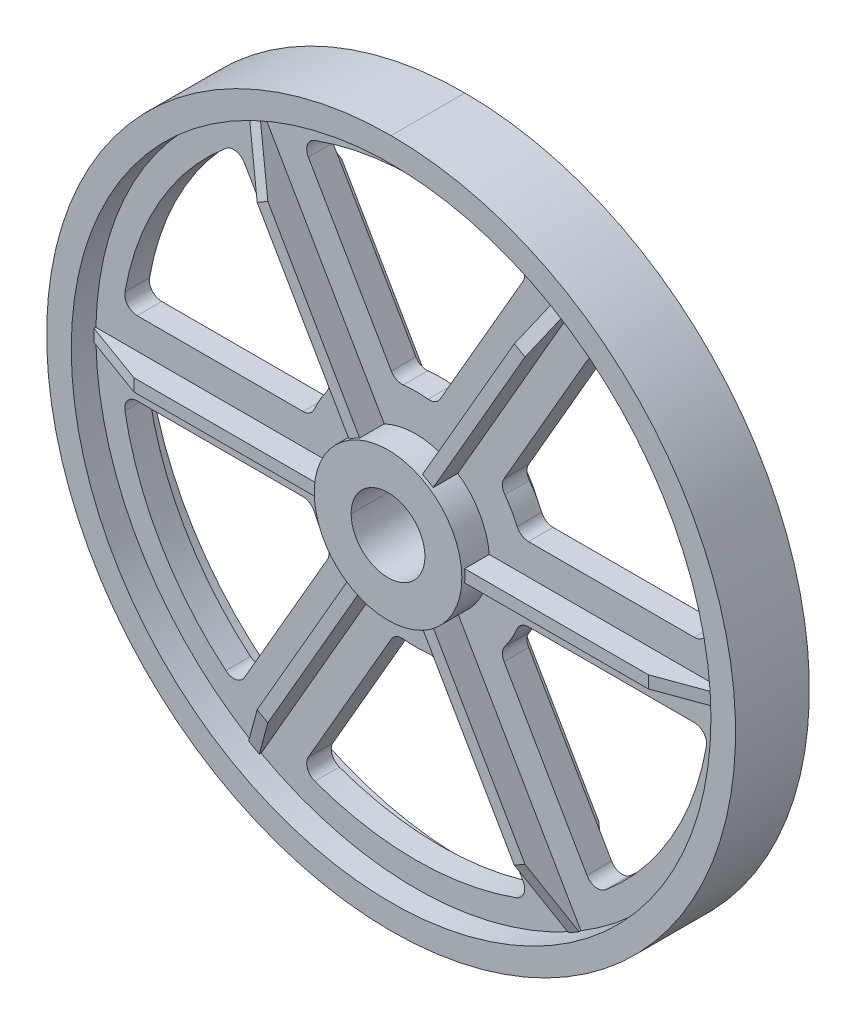
from build123d import *

# Parameters (mm, degrees)
SKETCH1_R                = 38.1
CENTERHUB_DEPTH          = 20.6375
RIB_DEPTH                = 3.175
LIGHTENING_HOLE_DEPTH    = 21.6375
FILLET1_R                = 6.35
CIRPATTERN1_COUNT        = 6
FILLET1_OF_CIRPATTERN1_R = 6.35
SKETCH5_R                = 19.05
THRU_HOLE_DEPTH          = 21.6375
THRU_HOLE_DEPTH_BACK     = 21.6375


with BuildPart() as part:
    # Sketch1 → CenterHub (new body, symmetric)
    with BuildSketch(Plane.XY):
        Circle(SKETCH1_R)
    extrude(amount=CENTERHUB_DEPTH, both=True)

    # Sketch2 → Rim and Web (revolve)
    with BuildSketch(Plane(origin=(0, 0, 0), x_dir=(0, 0, -1), z_dir=(1, 0, 0))):
        Polygon((-6.35, 0), (6.35, 0), (6.35, 165.1), (19.05, 165.1), (19.05, 177.8), (-19.05, 177.8), (-19.05, 165.1), (-6.35, 165.1), align=None)
    revolve(axis=Axis((0, 0, 0), (0, 0, -1)))

    # Sketch3 → Rib (add, symmetric)
    with BuildSketch(Plane(origin=(0, 0, 0), x_dir=(1, 0, 0), z_dir=(0, 1, 0))):
        Polygon((0, -19.05), (132.747036773, -19.05), (167.64, -6.35), (167.64, 6.35), (132.747036773, 19.05), (0, 19.05), align=None)
    rib = extrude(amount=RIB_DEPTH, both=True)

    # Sketch4 → Lightening hole (cut, symmetric)
    with BuildSketch(Plane.XY):
        with BuildLine():
            Line((92.100127656, -121.422100483), (43.438552305, -37.1377796))
            ThreePointArc((43.438552305, -37.1377796), (49.493351826, -28.575), (53.881536726, -19.05))
            Line((53.881536726, -19.05), (151.204687427, -19.05))
            ThreePointArc((151.204687427, -19.05), (131.982271537, -76.2), (92.100127656, -121.422100483))
        make_face()
    lightening_hole = extrude(amount=LIGHTENING_HOLE_DEPTH, both=True, mode=Mode.SUBTRACT)

    # Fillet1
    fillet1_edges = [part.edges().sort_by_distance(p)[0] for p in [
        (151.204687427, -19.05, 0),
        (92.100127656, -121.422100483, 0),
        (43.438552305, -37.1377796, 0),
        (53.881536726, -19.05, 0),
    ]]
    fillet(fillet1_edges, radius=FILLET1_R)

    # CirPattern1: Rib, Lightening hole ×6 about axis
    cirpattern1_axis = Axis((0, 0, 0), (0, 0, 1))
    for i in range(1, CIRPATTERN1_COUNT):
        add(rib.rotate(cirpattern1_axis, i * 360 / CIRPATTERN1_COUNT))
        add(lightening_hole.rotate(cirpattern1_axis, i * 360 / CIRPATTERN1_COUNT), mode=Mode.SUBTRACT)

    # Fillet1 of CirPattern1
    fillet1_of_cirpattern1_edges = [part.edges().sort_by_distance(p)[0] for p in [
        (92.100127656, 121.422100483, 0),
        (151.204687427, 19.05, 0),
        (53.881536726, 19.05, 0),
        (43.438552305, 37.1377796, 0),
        (-59.104559772, 140.472100483, 0),
        (59.104559772, 140.472100483, 0),
        (10.442984421, 56.1877796, 0),
        (-10.442984421, 56.1877796, 0),
        (-151.204687427, 19.05, 0),
        (-92.100127656, 121.422100483, 0),
        (-43.438552305, 37.1377796, 0),
        (-53.881536726, 19.05, 0),
        (-92.100127656, -121.422100483, 0),
        (-151.204687427, -19.05, 0),
        (-53.881536726, -19.05, 0),
        (-43.438552305, -37.1377796, 0),
        (59.104559772, -140.472100483, 0),
        (-59.104559772, -140.472100483, 0),
        (-10.442984421, -56.1877796, 0),
        (10.442984421, -56.1877796, 0),
    ]]
    fillet(fillet1_of_cirpattern1_edges, radius=FILLET1_OF_CIRPATTERN1_R)

    # Sketch5 → Thru hole (cut, two sides)
    with BuildSketch(Plane.XY) as thru_hole_sk:
        Circle(SKETCH5_R)
    extrude(amount=THRU_HOLE_DEPTH, mode=Mode.SUBTRACT)
    extrude(thru_hole_sk.sketch, amount=-THRU_HOLE_DEPTH_BACK, mode=Mode.SUBTRACT)


solid = part.part
